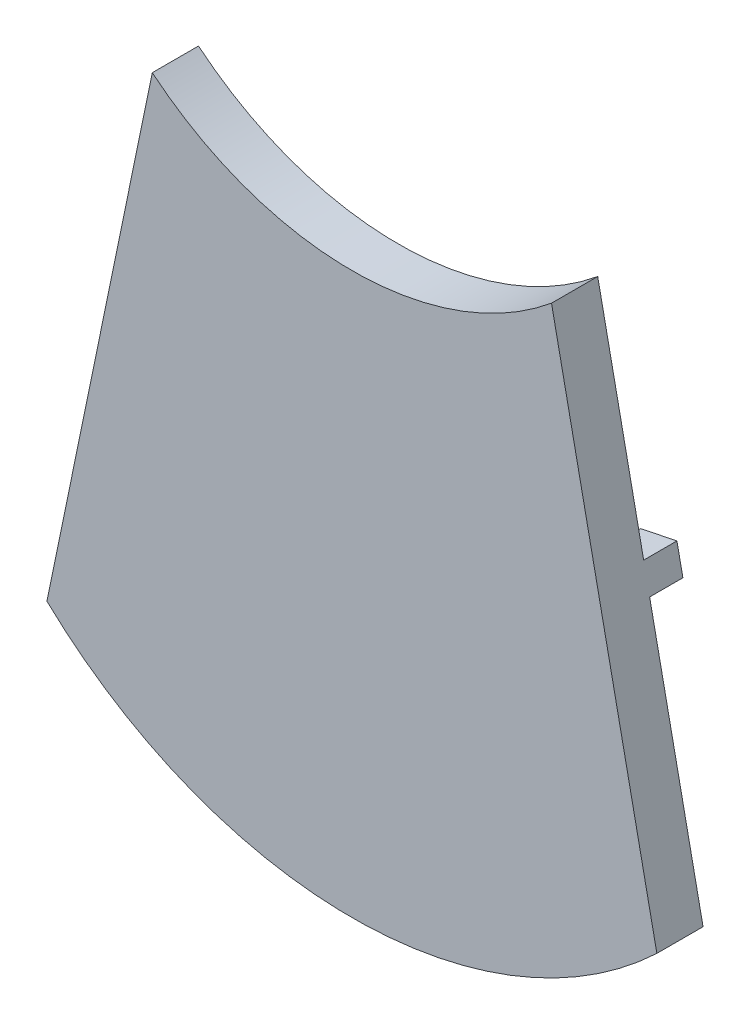
from build123d import *

# Parameters (mm, degrees)
BOSS_EXTRUDE1_DEPTH     = 15.875
BOSS_EXTRUDE2_DEPTH     = 11.43
CUT_EXTRUDE1_DEPTH      = 12.43
CUT_EXTRUDE1_DEPTH_BACK = 11.1125


with BuildPart() as part:
    # Sketch1 → Boss-Extrude1 (new body)
    with BuildSketch(Plane.XY):
        with BuildLine():
            Line((0, 0), (36.195, 175.373848891))
            ThreePointArc((36.195, 175.373848891), (104.775, 150.790425527), (173.355, 175.373848891))
            Line((173.355, 175.373848891), (209.55, 0))
            ThreePointArc((209.55, 0), (104.775, -41.729500882), (0, 0))
        make_face()
    extrude(amount=BOSS_EXTRUDE1_DEPTH)

    # Sketch2 → Boss-Extrude2 (add)
    with BuildSketch(Plane.XY):
        Polygon((20.407819149, 98.880999907), (39.064611584, 95.030467992), (37.010994563, 85.080178693), (18.354202128, 88.930710608), align=None)
        Polygon((189.142180851, 98.880999907), (170.485388416, 95.030467992), (172.539005437, 85.080178693), (191.195797872, 88.930710608), align=None)
        with BuildLine():
            Line((121.447738693, -20.993053202), (120.65, -14.693361703))
            Line((120.65, -14.693361703), (88.9, -14.693361703))
            Line((88.9, -14.693361703), (88.102261307, -20.993053202))
            ThreePointArc((88.102261307, -20.993053202), (104.775, -22.044500882), (121.447738693, -20.993053202))
        make_face()
    extrude(amount=-BOSS_EXTRUDE2_DEPTH)

    # Sketch4 → Cut-Extrude1 (cut, two sides)
    with BuildSketch(Plane(origin=(0, 0, 0), x_dir=(-1, 0, 0), z_dir=(0, 0, -1))) as cut_extrude1_sk:
        with BuildLine():
            Line((-174.137297951, 108.751840254), (-181.324957525, 73.925827708))
            Line((-181.324957525, 73.925827708), (-192.270924578, 20.889873244))
            ThreePointArc((-192.270924578, 20.889873244), (-104.775, -14.693361703), (-17.279075422, 20.889873244))
            Line((-17.279075422, 20.889873244), (-28.225042475, 73.925827708))
            Line((-28.225042475, 73.925827708), (-35.412702049, 108.751840254))
            Line((-35.412702049, 108.751840254), (-44.766321163, 154.072469762))
            ThreePointArc((-44.766321163, 154.072469762), (-104.775, 138.090425527), (-164.783678837, 154.072469762))
            Line((-164.783678837, 154.072469762), (-174.137297951, 108.751840254))
        make_face()
    extrude(amount=CUT_EXTRUDE1_DEPTH, mode=Mode.SUBTRACT)
    extrude(cut_extrude1_sk.sketch, amount=-CUT_EXTRUDE1_DEPTH_BACK, mode=Mode.SUBTRACT)


solid = part.part
